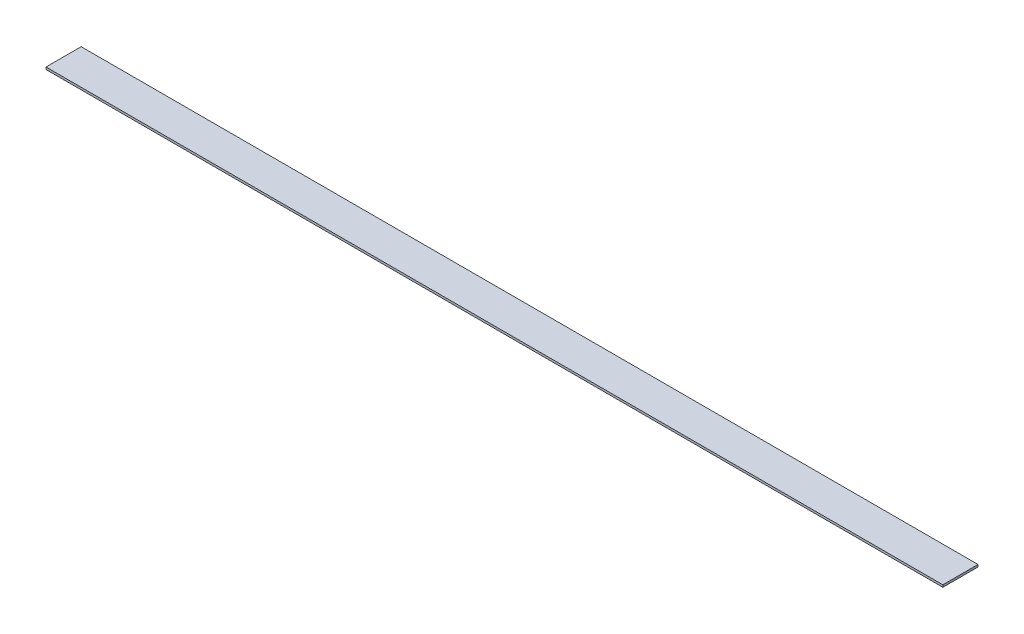
from build123d import *

# Parameters (mm, degrees)
SKETCH1_W           = 2590.8
SKETCH1_H           = 101.6
BOSS_EXTRUDE1_DEPTH = 6.35


with BuildPart() as part:
    # Sketch1 → Boss-Extrude1 (new body)
    with BuildSketch(Plane(origin=(0, 0, 0), x_dir=(1, 0, 0), z_dir=(0, 1, 0))):
        Rectangle(SKETCH1_W, SKETCH1_H)
    extrude(amount=BOSS_EXTRUDE1_DEPTH)


solid = part.part
